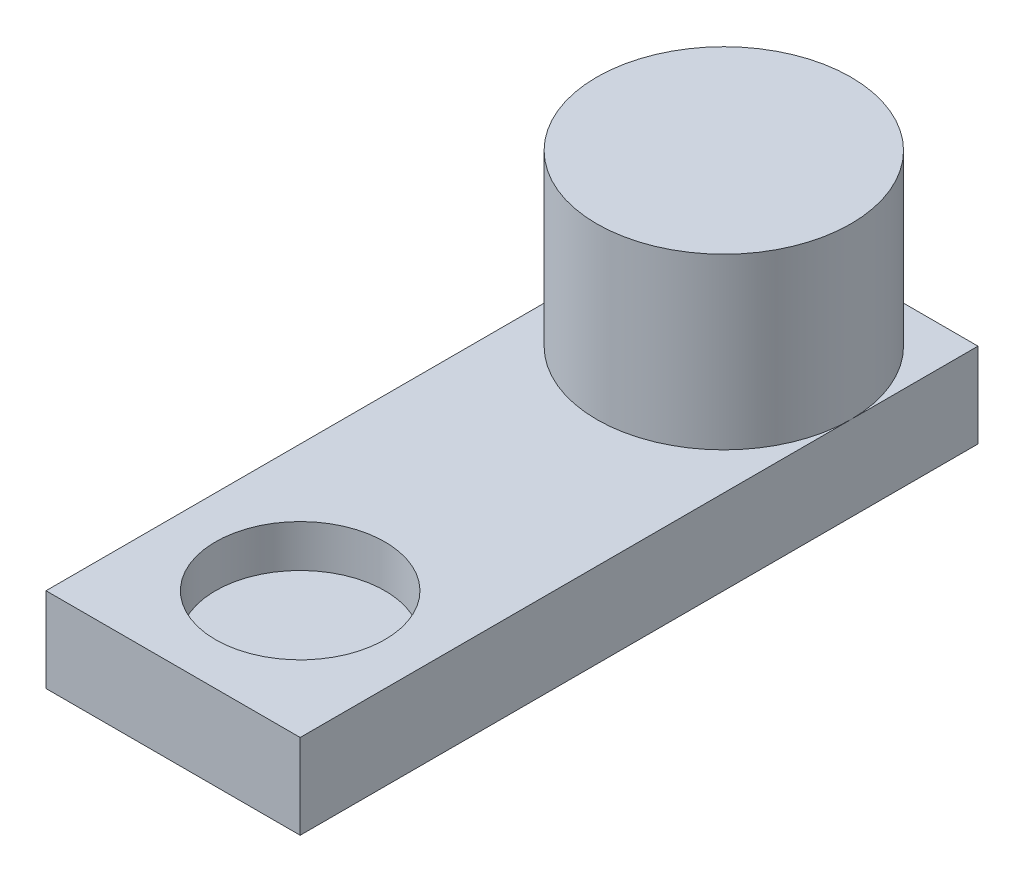
from build123d import *

# Parameters (mm, degrees)
SKETCH1_W           = 30
SKETCH1_H           = 80
BOSS_EXTRUDE1_DEPTH = 10
SKETCH2_R           = 15
BOSS_EXTRUDE2_DEPTH = 20
SKETCH3_R           = 10
CUT_EXTRUDE1_DEPTH  = 5


with BuildPart() as part:
    # Sketch1 → Boss-Extrude1 (new body)
    with BuildSketch(Plane(origin=(0, 0, 0), x_dir=(1, 0, 0), z_dir=(0, 1, 0))):
        Rectangle(SKETCH1_W, SKETCH1_H)
    extrude(amount=BOSS_EXTRUDE1_DEPTH)

    # Sketch2 → Boss-Extrude2 (add)
    with BuildSketch(Plane(origin=(0, 10, 0), x_dir=(1, 0, 0), z_dir=(0, 1, 0))):
        with Locations((0, 25)):
            Circle(SKETCH2_R)
    extrude(amount=BOSS_EXTRUDE2_DEPTH)

    # Sketch3 → Cut-Extrude1 (cut)
    with BuildSketch(Plane(origin=(0, 10, 0), x_dir=(1, 0, 0), z_dir=(0, 1, 0))):
        with Locations((0, -25)):
            Circle(SKETCH3_R)
    extrude(amount=-CUT_EXTRUDE1_DEPTH, mode=Mode.SUBTRACT)


solid = part.part
